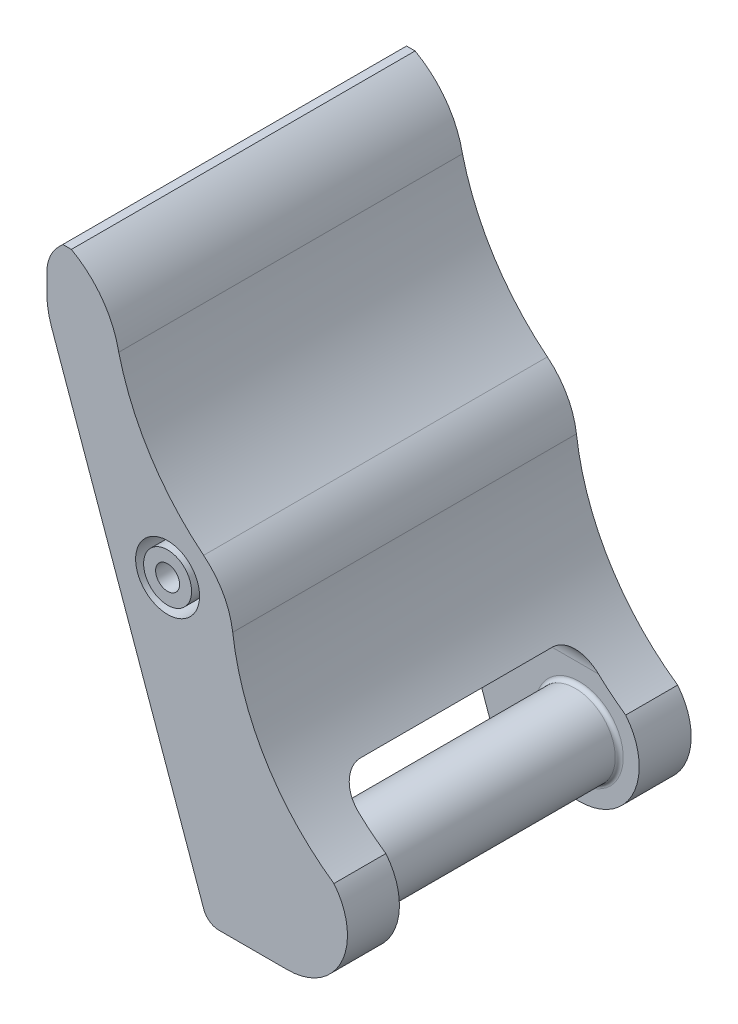
from build123d import *

# Parameters (mm, degrees)
EXTRUDE_1_DEPTH     = 21.5
FILLET_1_R          = 10
FILLET_2_R          = 2
CHAMFER_1_SIZE      = 2
FILLET_3_R          = 5
SKETCH_4_W          = 30
SKETCH_4_H          = 18
CUT_EXTRUDE_1_DEPTH = 41.107755842
FILLET_4_R          = 3
SKETCH_5_R          = 5
EXTRUDE_2_DEPTH     = 30
FILLET_5_R          = 0.5
CUT_EXTRUDE_2_DEPTH = 1
EXTRUDE_3_DEPTH     = 1
SKETCH_8_R          = 1.5
CUT_EXTRUDE_3_DEPTH = 44.0000001
SKETCH_9_R          = 4
SKETCH_9_R_2        = 3
CUT_EXTRUDE_4_DEPTH = 5


with BuildPart() as part:
    # 草图1 → 凸台-拉伸1 (new body, symmetric)
    with BuildSketch(Plane.XY):
        with BuildLine():
            Line((0, 0), (10, 0))
            ThreePointArc((10, 0), (16.777957438, 4.289191228), (15.803393387, 12.250855207))
            ThreePointArc((15.803393387, 12.250855207), (7.253184255, 21.345959317), (3.144852512, 33.133605616))
            ThreePointArc((3.144852512, 33.133605616), (1.958203293, 36.748513507), (-0.492803877, 39.658540875))
            ThreePointArc((-0.492803877, 39.658540875), (-7.169500574, 47.134089923), (-11.111969773, 56.349243149))
            ThreePointArc((-11.111969773, 56.349243149), (-13.171238931, 61.093425309), (-17.035891996, 64.530329514))
            Line((-17.035891996, 64.530329514), (-20.107755842, 64.530329514))
            Line((-20.107755842, 64.530329514), (-20.107755842, 56.530329514))
            Line((-20.107755842, 56.530329514), (0, 0))
        make_face()
    extrude(amount=EXTRUDE_1_DEPTH, both=True)

    # 圆角1
    fillet_1_edges = [part.edges().sort_by_distance(p)[0] for p in [
        (-20.107755842, 56.530329514, 0),
    ]]
    fillet(fillet_1_edges, radius=FILLET_1_R)

    # 圆角2
    fillet_2_edges = [part.edges().sort_by_distance(p)[0] for p in [
        (0, 0, 0),
    ]]
    fillet(fillet_2_edges, radius=FILLET_2_R)

    # 倒角1
    chamfer_1_edges = [part.edges().sort_by_distance(p)[0] for p in [
        (-20.107755842, 64.530329514, 0),
    ]]
    chamfer(chamfer_1_edges, length=CHAMFER_1_SIZE)

    # 圆角3
    fillet_3_edges = [part.edges().sort_by_distance(p)[0] for p in [
        (-20.107755842, 62.530329514, 0),
    ]]
    fillet(fillet_3_edges, radius=FILLET_3_R)

    # 草图4 → 切除-拉伸1 (cut, through all)
    with BuildSketch(Plane(origin=(20, 0, 0), x_dir=(0, 0, -1), z_dir=(1, 0, 0))):
        with Locations((0, 9)):
            Rectangle(SKETCH_4_W, SKETCH_4_H)
    extrude(amount=-CUT_EXTRUDE_1_DEPTH, mode=Mode.SUBTRACT)

    # 圆角4
    fillet_4_edges = [part.edges().sort_by_distance(p)[0] for p in [
        (1.602536732, 18, 15),
        (1.602536732, 18, -15),
    ]]
    fillet(fillet_4_edges, radius=FILLET_4_R)

    # 草图5 → 凸台-拉伸2 (add)
    with BuildSketch(Plane.XY.offset(-15)):
        with Locations((10, 7.5)):
            Circle(SKETCH_5_R)
    extrude(amount=EXTRUDE_2_DEPTH)

    # 圆角5
    fillet_5_edges = [part.edges().sort_by_distance(p)[0] for p in [
        (5, 7.5, -15),
        (5, 7.5, 15),
    ]]
    fillet(fillet_5_edges, radius=FILLET_5_R)

    # 草图6 → 切除-拉伸2 (cut)
    with BuildSketch(Plane(origin=(0, 0, 0), x_dir=(0, 0, 1), z_dir=(-0.942172159, -0.335129264, 0))):
        with BuildLine():
            Line((-9, 44.274461599), (9, 44.274461599))
            ThreePointArc((9, 44.274461599), (15, 38.274461599), (9, 32.274461599))
            Line((9, 32.274461599), (-9, 32.274461599))
            ThreePointArc((-9, 32.274461599), (-15, 38.274461599), (-9, 44.274461599))
        make_face()
    extrude(amount=-CUT_EXTRUDE_2_DEPTH, mode=Mode.SUBTRACT)

    # 草图7 → 凸台-拉伸3 (add)
    with BuildSketch(Plane(origin=(0.942172159, 0.335129264, 0), x_dir=(0, 0, 1), z_dir=(-0.942172159, -0.335129264, 0))):
        with BuildLine():
            Line((-8.417101523, 39.476144957), (-8.316419656, 39.783411099))
            Line((-8.316419656, 39.783411099), (-8.216483581, 39.778190557))
            Line((-8.216483581, 39.778190557), (-8.216483581, 38.52004012))
            Line((-8.216483581, 38.52004012), (-8.336556029, 38.514819579))
            Line((-8.336556029, 38.514819579), (-8.40666044, 39.048060576))
            add(Edge.make_bspline(
                [(-8.40666044, 39.048060576), (-8.416417829, 39.077797435), (-8.434613801, 39.133251923), (-8.466239834, 39.208160255), (-8.499805241, 39.268674041), (-8.535325718, 39.317468794), (-8.575497585, 39.357156801), (-8.61889069, 39.394825108), (-8.668408654, 39.430572463), (-8.723678879, 39.464577094), (-8.78387418, 39.49759227), (-8.84994874, 39.52743471), (-8.921737501, 39.554245618), (-9.025102803, 39.58563279), (-9.160690665, 39.617442753), (-9.272315315, 39.624161396), (-9.328458863, 39.627540653)],
                knots=[0, 0, 0, 0, 9.3869e-05, 0.000175051, 0.000243505, 0.000301081, 0.000355401, 0.000412512, 0.000473375, 0.000538357, 0.000607104, 0.000679195, 0.00075566, 0.000836811, 0.001003288, 0.001171752, 0.001171752, 0.001171752, 0.001171752], degree=3))
            add(Edge.make_bspline(
                [(-9.328458863, 39.627540653), (-9.362300887, 39.62684109), (-9.430936335, 39.625422298), (-9.517784573, 39.615080944), (-9.591370785, 39.601944581), (-9.652428291, 39.583983063), (-9.719570209, 39.56108533), (-9.789735842, 39.531815955), (-9.859228596, 39.499049515), (-9.922545225, 39.460709833), (-9.978028271, 39.418626329), (-10.024232996, 39.37191132), (-10.062713871, 39.324177375), (-10.095367962, 39.277048975), (-10.121009072, 39.229839439), (-10.140308971, 39.181511198), (-10.15356008, 39.129794032), (-10.164321251, 39.07278181), (-10.169903089, 39.008601557), (-10.175892929, 38.939526172), (-10.17188991, 38.867097017), (-10.15008854, 38.796402105), (-10.112857836, 38.729139204), (-10.077616557, 38.690654513), (-10.059334636, 38.670690025)],
                knots=[0, 0, 0, 0, 0.000101496, 0.000205846, 0.000262013, 0.000325528, 0.00039652, 0.000474771, 0.00055349, 0.000626779, 0.000696442, 0.000761834, 0.000823333, 0.000880219, 0.000933609, 0.000984159, 0.001035898, 0.001093532, 0.001158021, 0.001229012, 0.001301542, 0.001373976, 0.001449094, 0.00153007, 0.00153007, 0.00153007, 0.00153007], degree=3))
            add(Edge.make_bspline(
                [(-10.059334636, 38.670690025), (-10.037964617, 38.651404548), (-9.99424021, 38.611945247), (-9.917153461, 38.563598162), (-9.829578846, 38.524250813), (-9.73443606, 38.493312488), (-9.63793449, 38.470433962), (-9.547588409, 38.446890279), (-9.465036215, 38.42956343), (-9.412739362, 38.419074881), (-9.388122192, 38.414137713)],
                knots=[0, 0, 0, 0, 8.6232e-05, 0.000176435, 0.00027155, 0.000373669, 0.000476049, 0.000569022, 0.000653717, 0.000729042, 0.000729042, 0.000729042, 0.000729042], degree=3))
            Line((-9.388122192, 38.414137713), (-9.037600138, 38.34328751))
            add(Edge.make_bspline(
                [(-9.037600138, 38.34328751), (-8.994538912, 38.333313901), (-8.91217705, 38.31423769), (-8.794866713, 38.283424108), (-8.689121789, 38.253544448), (-8.594915095, 38.221858059), (-8.510381487, 38.18937593), (-8.433504413, 38.156479782), (-8.364702382, 38.12040836), (-8.302970028, 38.083072485), (-8.248093018, 38.043737621), (-8.200174477, 38.000806784), (-8.15989466, 37.95367438), (-8.115368259, 37.886601591), (-8.071087137, 37.796425177), (-8.033728905, 37.679682736), (-8.010045697, 37.552438984), (-8.000792419, 37.439858151), (-8.001524857, 37.345567425), (-8.011900649, 37.27516386), (-8.028151594, 37.205851396), (-8.046783262, 37.162228893), (-8.056138386, 37.140325652)],
                knots=[0, 0, 0, 0, 0.000132596, 0.000253612, 0.00036384, 0.000462186, 0.000551659, 0.000635487, 0.000712877, 0.000784504, 0.000851782, 0.000915144, 0.000977027, 0.001037219, 0.001156289, 0.001277043, 0.001403856, 0.001543767, 0.001615378, 0.00168615, 0.001756875, 0.001828198, 0.001828198, 0.001828198, 0.001828198], degree=3))
            add(Edge.make_bspline(
                [(-8.056138386, 37.140325652), (-8.066745046, 37.117139572), (-8.08806702, 37.070529892), (-8.130834842, 37.005993399), (-8.179255229, 36.943896095), (-8.23572964, 36.887944827), (-8.294552992, 36.836493267), (-8.353764045, 36.790542636), (-8.412665236, 36.751088358), (-8.472174209, 36.716368189), (-8.536279256, 36.686365858), (-8.608331828, 36.659999499), (-8.689330095, 36.634558415), (-8.779725752, 36.612367851), (-8.878262264, 36.593830975), (-8.984823535, 36.580292215), (-9.09890951, 36.573304873), (-9.177552046, 36.571973039), (-9.218081706, 36.571286658)],
                knots=[0, 0, 0, 0, 7.6381e-05, 0.000153544, 0.000231582, 0.000312269, 0.000391548, 0.000465985, 0.000536933, 0.000604092, 0.000672485, 0.00074895, 0.000834104, 0.000927077, 0.001028005, 0.001134754, 0.001249104, 0.001370705, 0.001370705, 0.001370705, 0.001370705], degree=3))
            add(Edge.make_bspline(
                [(-9.218081706, 36.571286658), (-9.263594024, 36.571429583), (-9.352266503, 36.571708045), (-9.481667202, 36.582158625), (-9.603694057, 36.601227793), (-9.718063093, 36.629761782), (-9.825180547, 36.665713541), (-9.925233362, 36.708041455), (-10.018239531, 36.757104924), (-10.105037475, 36.810620999), (-10.182512879, 36.87225439), (-10.252007262, 36.938537119), (-10.311036911, 37.011568658), (-10.360913192, 37.088541688), (-10.400087383, 37.168231572), (-10.429930578, 37.247165314), (-10.451236689, 37.324810954), (-10.456994338, 37.376626586), (-10.459824727, 37.402098505)],
                knots=[0, 0, 0, 0, 0.000136498, 0.000265942, 0.000389043, 0.000506616, 0.000619111, 0.000727713, 0.000832127, 0.000934344, 0.001033115, 0.00112858, 0.001221878, 0.001314142, 0.001403195, 0.00148769, 0.001567102, 0.001643886, 0.001643886, 0.001643886, 0.001643886], degree=3))
            Line((-10.459824727, 37.402098505), (-10.499351683, 37.6690919))
            Line((-10.499351683, 37.6690919), (-10.359888652, 37.6690919))
            add(Edge.make_bspline(
                [(-10.359888652, 37.6690919), (-10.351634666, 37.637465394), (-10.335713668, 37.576461474), (-10.30937037, 37.488730125), (-10.282628232, 37.407953955), (-10.255933255, 37.332877868), (-10.226231112, 37.263383267), (-10.190875955, 37.198792183), (-10.150295831, 37.138494248), (-10.105791864, 37.080817089), (-10.053349205, 37.028810295), (-9.995865664, 36.978883368), (-9.930608766, 36.933639234), (-9.859351816, 36.892405315), (-9.784631877, 36.855262315), (-9.70703555, 36.825578611), (-9.628670216, 36.80122106), (-9.523233162, 36.779364893), (-9.392882852, 36.762765421), (-9.288981089, 36.762892845), (-9.238218079, 36.7629551)],
                knots=[0, 0, 0, 0, 9.8051e-05, 0.000189129, 0.00027474, 0.000353303, 0.00042812, 0.000501212, 0.000573814, 0.000646029, 0.000719333, 0.000794968, 0.000874212, 0.000957098, 0.001041817, 0.001124223, 0.001206087, 0.001287709, 0.001447002, 0.001599173, 0.001599173, 0.001599173, 0.001599173], degree=3))
            add(Edge.make_bspline(
                [(-9.238218079, 36.7629551), (-9.193435432, 36.763782214), (-9.107654964, 36.765366537), (-8.984976686, 36.778150036), (-8.8738808, 36.798216311), (-8.774312928, 36.828448587), (-8.68493505, 36.866126789), (-8.603898157, 36.909378037), (-8.530711848, 36.958632007), (-8.467382357, 37.014285102), (-8.413416842, 37.07232671), (-8.36821035, 37.128856365), (-8.334816381, 37.185023823), (-8.310672362, 37.240102516), (-8.295532522, 37.297499603), (-8.287207994, 37.358325372), (-8.283036211, 37.424202142), (-8.285370312, 37.469469506), (-8.286587992, 37.493085081)],
                knots=[0, 0, 0, 0, 0.000134317, 0.000257282, 0.000369617, 0.000472483, 0.000568747, 0.000660173, 0.000747673, 0.000832775, 0.000912449, 0.00098525, 0.001049458, 0.00110792, 0.001165089, 0.001226895, 0.001291886, 0.001362772, 0.001362772, 0.001362772, 0.001362772], degree=3))
            add(Edge.make_bspline(
                [(-8.286587992, 37.493085081), (-8.292376734, 37.530066312), (-8.303288842, 37.599778028), (-8.332685966, 37.695662427), (-8.373084953, 37.775948345), (-8.424695222, 37.841255801), (-8.485607221, 37.894383317), (-8.552467892, 37.942280672), (-8.62632204, 37.985869063), (-8.709267653, 38.022995948), (-8.801728219, 38.057668631), (-8.905855484, 38.090040767), (-9.022548582, 38.120728902), (-9.104884242, 38.138068877), (-9.147977295, 38.147144318)],
                knots=[0, 0, 0, 0, 0.000112199, 0.000211501, 0.000299558, 0.000380276, 0.000459492, 0.000541247, 0.000626818, 0.000716254, 0.000813494, 0.00092294, 0.001043234, 0.001175332, 0.001175332, 0.001175332, 0.001175332], degree=3))
            Line((-9.147977295, 38.147144318), (-9.578299051, 38.227689812))
            add(Edge.make_bspline(
                [(-9.578299051, 38.227689812), (-9.612691087, 38.234526193), (-9.680091354, 38.247923885), (-9.777603188, 38.273904078), (-9.870689006, 38.301075664), (-9.958095621, 38.332188757), (-10.039384412, 38.366295408), (-10.113803017, 38.403290019), (-10.179953199, 38.444635499), (-10.240082976, 38.487603064), (-10.291673124, 38.536123496), (-10.337549418, 38.587683454), (-10.377353444, 38.643377729), (-10.411578473, 38.703109738), (-10.437440226, 38.769610542), (-10.454138786, 38.842666079), (-10.462573371, 38.923083409), (-10.460769014, 38.97868793), (-10.459824727, 39.00778783)],
                knots=[0, 0, 0, 0, 0.000105167, 0.000206103, 0.00030261, 0.000396022, 0.000484256, 0.000566971, 0.000644998, 0.00071809, 0.000788277, 0.000856963, 0.000924847, 0.000993301, 0.001062964, 0.001138037, 0.001217516, 0.001304777, 0.001304777, 0.001304777, 0.001304777], degree=3))
            add(Edge.make_bspline(
                [(-10.459824727, 39.00778783), (-10.459104336, 39.032935787), (-10.457706916, 39.081717993), (-10.447062749, 39.152226335), (-10.430253547, 39.217419045), (-10.405823569, 39.27768373), (-10.374199788, 39.333827086), (-10.338963199, 39.389323725), (-10.296308268, 39.442168911), (-10.249998546, 39.494210824), (-10.198882141, 39.542806885), (-10.145085726, 39.587663212), (-10.08913213, 39.628398127), (-10.008534459, 39.675915774), (-9.897118286, 39.725817082), (-9.776336741, 39.766645756), (-9.667702863, 39.791224331), (-9.57393313, 39.804284406), (-9.46952175, 39.811331907), (-9.396585047, 39.812584896), (-9.358290528, 39.813242763)],
                knots=[0, 0, 0, 0, 7.5417e-05, 0.000146295, 0.000213408, 0.000276975, 0.000340722, 0.000406504, 0.000473944, 0.000544179, 0.000615389, 0.000685287, 0.000754211, 0.000822767, 0.000965594, 0.001119597, 0.001204454, 0.001299378, 0.001403311, 0.001518201, 0.001518201, 0.001518201, 0.001518201], degree=3))
            add(Edge.make_bspline(
                [(-9.358290528, 39.813242763), (-9.315483408, 39.810820357), (-9.231348364, 39.806059251), (-9.10748452, 39.789371411), (-8.98802497, 39.765025563), (-8.874903885, 39.732388914), (-8.771060859, 39.69538259), (-8.679232297, 39.657673649), (-8.602138613, 39.616643073), (-8.557811632, 39.585913358), (-8.537173971, 39.571606283)],
                knots=[0, 0, 0, 0, 0.000128588, 0.000252733, 0.000374571, 0.000494019, 0.000605591, 0.000705184, 0.000791609, 0.000866901, 0.000866901, 0.000866901, 0.000866901], degree=3))
            Line((-8.537173971, 39.571606283), (-8.417101523, 39.476144957))
        make_face()
        with BuildLine():
            Line((-5.258674078, 38.247826185), (-3.466536852, 38.353728593))
            Line((-3.466536852, 38.353728593), (-3.466536852, 39.24494956))
            add(Edge.make_bspline(
                [(-3.466536852, 39.24494956), (-3.466919533, 39.27653867), (-3.467761296, 39.346023519), (-3.475586787, 39.434661249), (-3.481432416, 39.508598754), (-3.488095944, 39.558636239), (-3.495964223, 39.600836275), (-3.509167478, 39.646555544), (-3.528579924, 39.698636593), (-3.547283387, 39.738048114), (-3.556777636, 39.758054184)],
                knots=[0, 0, 0, 0, 9.4742e-05, 0.000208399, 0.000266804, 0.000317221, 0.000359784, 0.000395434, 0.000459853, 0.000526266, 0.000526266, 0.000526266, 0.000526266], degree=3))
            Line((-3.556777636, 39.758054184), (-3.597050383, 39.838599677))
            Line((-3.597050383, 39.838599677), (-3.506809599, 39.889313506))
            Line((-3.506809599, 39.889313506), (-3.075742051, 39.587267907))
            add(Edge.make_bspline(
                [(-3.075742051, 39.587267907), (-3.087223573, 39.57056542), (-3.107335712, 39.541307735), (-3.132520381, 39.496266803), (-3.149505088, 39.445737439), (-3.16442167, 39.396312141), (-3.176274188, 39.345530572), (-3.181439433, 39.297010356), (-3.185289837, 39.240786374), (-3.18583061, 39.200708525), (-3.186119209, 39.179319899)],
                knots=[0, 0, 0, 0, 6.0813e-05, 0.000106526, 0.000154186, 0.000220264, 0.000261519, 0.000310361, 0.00036642, 0.000430575, 0.000430575, 0.000430575, 0.000430575], degree=3))
            Line((-3.186119209, 39.179319899), (-3.186119209, 37.145546193))
            Line((-3.186119209, 37.145546193), (-3.226391955, 36.607084655))
            add(Edge.make_bspline(
                [(-3.226391955, 36.607084655), (-3.228163614, 36.594660305), (-3.231389325, 36.572038919), (-3.235370865, 36.541041065), (-3.240666568, 36.516432619), (-3.246869385, 36.493414657), (-3.255159004, 36.473021697), (-3.268516602, 36.457538541), (-3.284896616, 36.452898777), (-3.292669047, 36.458266375), (-3.296496366, 36.4609095)],
                knots=[0, 0, 0, 0, 3.7653e-05, 6.8556e-05, 9.3715e-05, 0.000113077, 0.000140111, 0.000159096, 0.000172848, 0.000186189, 0.000186189, 0.000186189, 0.000186189], degree=3))
            add(Edge.make_bspline(
                [(-3.296496366, 36.4609095), (-3.303726536, 36.464108), (-3.32344248, 36.472829987), (-3.331601894, 36.493385396), (-3.336769113, 36.506402788)],
                knots=[0, 0, 0, 0, 2.3035e-05, 6.2815e-05, 6.2815e-05, 6.2815e-05, 6.2815e-05], degree=3))
            Line((-3.336769113, 36.506402788), (-3.396432441, 36.566811908))
            Line((-3.396432441, 36.566811908), (-3.516504889, 36.742818727))
            add(Edge.make_bspline(
                [(-3.516504889, 36.742818727), (-3.529721133, 36.758564867), (-3.552364769, 36.785543023), (-3.577806782, 36.821525695), (-3.593627751, 36.846507644), (-3.592963541, 36.871412334), (-3.570818586, 36.889925251), (-3.550891359, 36.921032564), (-3.526071581, 36.959748784), (-3.506323782, 37.0069002), (-3.488857461, 37.05492869), (-3.477057383, 37.101002693), (-3.46771331, 37.142659821), (-3.466435504, 37.17486704), (-3.466566437, 37.201229669), (-3.466523298, 37.226341337), (-3.466542394, 37.261889253), (-3.466534793, 37.307880326), (-3.466537569, 37.364560272), (-3.466536612, 37.431681591), (-3.466536925, 37.509243893), (-3.466536877, 37.564432476), (-3.466536852, 37.593766948)],
                knots=[0, 0, 0, 0, 6.15e-05, 0.000105368, 0.000133393, 0.000147582, 0.000175775, 0.000213664, 0.000259837, 0.000312919, 0.000366699, 0.00041301, 0.000455572, 0.000494418, 0.000509334, 0.000534691, 0.000569743, 0.000615982, 0.000672662, 0.000739783, 0.000817346, 0.000905349, 0.000905349, 0.000905349, 0.000905349], degree=3))
            Line((-3.466536852, 37.593766948), (-3.466536852, 38.167280692))
            Line((-3.466536852, 38.167280692), (-5.26911516, 38.056903534))
            Line((-5.26911516, 38.056903534), (-5.258674078, 36.969539375))
            add(Edge.make_bspline(
                [(-5.258674078, 36.969539375), (-5.259474411, 36.940916951), (-5.261268297, 36.87676198), (-5.274393694, 36.778081225), (-5.286950553, 36.680091561), (-5.294003065, 36.595353202), (-5.299367458, 36.528633969), (-5.315691283, 36.479320789), (-5.334462898, 36.447863824), (-5.357698657, 36.428572447), (-5.38399707, 36.438366467), (-5.393388649, 36.452589032), (-5.398882899, 36.4609095)],
                knots=[0, 0, 0, 0, 8.5847e-05, 0.00019242, 0.000298338, 0.000382199, 0.000447599, 0.000498777, 0.000535389, 0.000559185, 0.000580186, 0.000609793, 0.000609793, 0.000609793, 0.000609793], degree=3))
            Line((-5.398882899, 36.4609095), (-5.46898731, 36.566811908))
            Line((-5.46898731, 36.566811908), (-5.58980555, 36.752514018))
            add(Edge.make_bspline(
                [(-5.58980555, 36.752514018), (-5.598802304, 36.764011847), (-5.614487637, 36.784057662), (-5.631568776, 36.812655414), (-5.643811529, 36.833175308), (-5.646577834, 36.856575847), (-5.631959844, 36.883626446), (-5.613340237, 36.923175887), (-5.586628622, 36.975458441), (-5.563911308, 37.039622417), (-5.543897596, 37.104861984), (-5.535923159, 37.153807904), (-5.532692084, 37.186772592), (-5.532414804, 37.210435425), (-5.531517607, 37.24100311), (-5.530834281, 37.278296919), (-5.530126375, 37.322297931), (-5.529160663, 37.373009226), (-5.529467811, 37.430687662), (-5.529421172, 37.47145729), (-5.52939643, 37.493085081)],
                knots=[0, 0, 0, 0, 4.3704e-05, 7.6195e-05, 0.000100211, 0.00011446, 0.000144662, 0.000188689, 0.000247398, 0.000319848, 0.000392787, 0.000451761, 0.000468236, 0.000492113, 0.000522699, 0.000559996, 0.000604004, 0.000654724, 0.00071215, 0.000777034, 0.000777034, 0.000777034, 0.000777034], degree=3))
            Line((-5.52939643, 37.493085081), (-5.52939643, 39.234508478))
            add(Edge.make_bspline(
                [(-5.52939643, 39.234508478), (-5.530233036, 39.266105294), (-5.532061919, 39.335178283), (-5.541856247, 39.423096259), (-5.551330651, 39.49608933), (-5.55850978, 39.546659478), (-5.566988167, 39.59029503), (-5.57645466, 39.638469036), (-5.588077002, 39.689532652), (-5.602586289, 39.726360898), (-5.609196132, 39.743138352)],
                knots=[0, 0, 0, 0, 9.4789e-05, 0.000207216, 0.000265124, 0.000315645, 0.000360405, 0.000398433, 0.000463008, 0.00051704, 0.00051704, 0.00051704, 0.00051704], degree=3))
            Line((-5.609196132, 39.743138352), (-5.659909961, 39.828904386))
            Line((-5.659909961, 39.828904386), (-5.569669177, 39.873651883))
            Line((-5.569669177, 39.873651883), (-5.128906338, 39.576826824))
            add(Edge.make_bspline(
                [(-5.128906338, 39.576826824), (-5.140736593, 39.560282023), (-5.161913618, 39.530665612), (-5.190743684, 39.485921681), (-5.213659514, 39.433824793), (-5.235834819, 39.370120369), (-5.255575457, 39.294714193), (-5.257643242, 39.241099949), (-5.258674078, 39.214372104)],
                knots=[0, 0, 0, 0, 6.1037e-05, 0.00010926, 0.000159317, 0.000231258, 0.000311755, 0.000391777, 0.000391777, 0.000391777, 0.000391777], degree=3))
            Line((-5.258674078, 39.214372104), (-5.258674078, 38.247826185))
        make_face()
        with BuildLine():
            Line((1.294596751, 37.900287297), (-0.067218719, 37.734721561))
            Line((-0.067218719, 37.734721561), (-0.387163317, 36.984455207))
            Line((-0.387163317, 36.984455207), (-0.537813221, 36.601864114))
            Line((-0.537813221, 36.601864114), (-0.597476549, 36.481045874))
            add(Edge.make_bspline(
                [(-0.597476549, 36.481045874), (-0.603783545, 36.472278646), (-0.615059436, 36.456604259), (-0.635778906, 36.439309826), (-0.657370673, 36.432634118), (-0.677923628, 36.430969162), (-0.697191474, 36.438756848), (-0.709240792, 36.454142291), (-0.714736702, 36.47474551), (-0.721541888, 36.500792229), (-0.729775744, 36.537573197), (-0.734831188, 36.565794605), (-0.737685371, 36.58172774)],
                knots=[0, 0, 0, 0, 3.238e-05, 5.789e-05, 7.9115e-05, 9.9266e-05, 0.000118656, 0.000138806, 0.000155315, 0.000182267, 0.00021972, 0.000268283, 0.000268283, 0.000268283, 0.000268283], degree=3))
            Line((-0.737685371, 36.58172774), (-0.787653409, 36.792786764))
            add(Edge.make_bspline(
                [(-0.787653409, 36.792786764), (-0.790564606, 36.810160416), (-0.795748848, 36.841099312), (-0.800363759, 36.882201489), (-0.801982887, 36.911878847), (-0.798709987, 36.938058941), (-0.781792201, 36.961307816), (-0.766251892, 36.976314523), (-0.757821744, 36.984455207)],
                knots=[0, 0, 0, 0, 5.2846e-05, 9.4108e-05, 0.000123949, 0.000142095, 0.000171899, 0.000207235, 0.000207235, 0.000207235, 0.000207235], degree=3))
            Line((-0.757821744, 36.984455207), (-0.707853707, 37.029948495))
            add(Edge.make_bspline(
                [(-0.707853707, 37.029948495), (-0.697057515, 37.041602592), (-0.672317333, 37.068308719), (-0.639694353, 37.121291482), (-0.604217751, 37.189312676), (-0.57454336, 37.255041286), (-0.549520884, 37.310263569), (-0.533005684, 37.348954133), (-0.516817604, 37.381909959), (-0.503580005, 37.410086006), (-0.492544602, 37.433415696), (-0.482927449, 37.451383086), (-0.474992899, 37.464166481), (-0.469742825, 37.470496352), (-0.46770881, 37.472948708)],
                knots=[0, 0, 0, 0, 4.7567e-05, 0.000109003, 0.000185733, 0.000277825, 0.000325229, 0.000367634, 0.000403995, 0.000435353, 0.000461037, 0.000481393, 0.000496495, 0.000506045, 0.000506045, 0.000506045, 0.000506045], degree=3))
            Line((-0.46770881, 37.472948708), (0.563720979, 39.873651883))
            Line((0.563720979, 39.873651883), (0.703929801, 39.873651883))
            Line((0.703929801, 39.873651883), (1.67495047, 37.714585188))
            Line((1.67495047, 37.714585188), (1.79576871, 37.462507625))
            add(Edge.make_bspline(
                [(1.79576871, 37.462507625), (1.807898178, 37.43402519), (1.82978905, 37.382621012), (1.863169839, 37.315374285), (1.889540334, 37.264044494), (1.908176394, 37.23715215), (1.915841158, 37.226091687)],
                knots=[0, 0, 0, 0, 9.2838e-05, 0.000167552, 0.000225287, 0.000265622, 0.000265622, 0.000265622, 0.000265622], degree=3))
            Line((1.915841158, 37.226091687), (1.985945569, 37.130630361))
            add(Edge.make_bspline(
                [(1.985945569, 37.130630361), (1.99418142, 37.116580733), (2.009432436, 37.090563857), (2.033837404, 37.056076646), (2.059335938, 37.030483511), (2.084168839, 37.012230797), (2.106589444, 37.00069039), (2.123448581, 36.990136208), (2.134383228, 36.981629588), (2.142652139, 36.973292338), (2.145219576, 36.959919577), (2.141218015, 36.945390035), (2.137173182, 36.926935357), (2.135120959, 36.903336062), (2.129833821, 36.871198035), (2.127475675, 36.846755069), (2.12615439, 36.833059511)],
                knots=[0, 0, 0, 0, 4.8859e-05, 9.0477e-05, 0.000126337, 0.000156769, 0.000182485, 0.000201933, 0.000216259, 0.000224187, 0.000236487, 0.000254633, 0.000269113, 0.000293164, 0.000325544, 0.000366806, 0.000366806, 0.000366806, 0.000366806], degree=3))
            Line((2.12615439, 36.833059511), (2.085881644, 36.607084655))
            Line((2.085881644, 36.607084655), (2.06574527, 36.52131862))
            add(Edge.make_bspline(
                [(2.06574527, 36.52131862), (2.064233264, 36.511574389), (2.061526065, 36.494127648), (2.054986519, 36.471478898), (2.047319723, 36.454902566), (2.034160331, 36.442159284), (2.013491428, 36.438989528), (1.99015765, 36.441438458), (1.967435088, 36.453578524), (1.959454393, 36.46829182), (1.955368113, 36.475825333)],
                knots=[0, 0, 0, 0, 2.9551e-05, 5.291e-05, 7.059e-05, 8.3784e-05, 0.000106033, 0.000130084, 0.000154135, 0.000179371, 0.000179371, 0.000179371, 0.000179371], degree=3))
            Line((1.955368113, 36.475825333), (1.885263702, 36.677189066))
            Line((1.885263702, 36.677189066), (1.294596751, 37.900287297))
        make_face()
        with BuildLine():
            Line((1.274460378, 37.976358041), (0.63382539, 39.390378923))
            Line((0.63382539, 39.390378923), (-0.017250681, 37.91072838))
            add(Edge.make_bspline(
                [(-0.017250681, 37.91072838), (0.012580148, 37.913222356), (0.068518168, 37.917898999), (0.146629043, 37.924310458), (0.213507261, 37.931061303), (0.272437903, 37.938013603), (0.329991053, 37.946387919), (0.392555148, 37.953890452), (0.462712405, 37.96521036), (0.537558197, 37.974878412), (0.609021606, 37.987515543), (0.670372016, 37.998141647), (0.717375799, 38.008596448), (0.743256469, 38.017460784), (0.753897838, 38.021105537)],
                knots=[0, 0, 0, 0, 8.9805e-05, 0.0001684, 0.000235114, 0.00029145, 0.000346401, 0.000409583, 0.00048046, 0.000559563, 0.000635948, 0.000698118, 0.000746416, 0.000780142, 0.000780142, 0.000780142, 0.000780142], degree=3))
            Line((0.753897838, 38.021105537), (1.004483817, 38.106871572))
            Line((1.004483817, 38.106871572), (1.274460378, 37.976358041))
        make_face(mode=Mode.SUBTRACT)
        with BuildLine():
            add(Edge.make_bspline(
                [(6.0162034, 38.212773979), (6.032091868, 38.201308581), (6.062134681, 38.179629158), (6.105169163, 38.149270303), (6.142158106, 38.120740042), (6.185953998, 38.087127304), (6.234592792, 38.039369714), (6.274974319, 37.963374901), (6.305609664, 37.873271402), (6.328642376, 37.769189523), (6.343578077, 37.654100752), (6.345571207, 37.574175106), (6.34658908, 37.533357828)],
                knots=[0, 0, 0, 0, 5.878e-05, 0.000111145, 0.000157982, 0.000198865, 0.00027692, 0.000360082, 0.000454197, 0.000562027, 0.000679323, 0.000801744, 0.000801744, 0.000801744, 0.000801744], degree=3))
            Line((6.34658908, 37.533357828), (6.376420744, 37.0650007))
            add(Edge.make_bspline(
                [(6.376420744, 37.0650007), (6.376818701, 37.03888803), (6.377589861, 36.988286974), (6.383314133, 36.926658462), (6.391751841, 36.882007554), (6.401433903, 36.853343961), (6.414899689, 36.829976636), (6.43176521, 36.807404492), (6.464262235, 36.793401503), (6.511572783, 36.784063481), (6.577965254, 36.779055277), (6.628503227, 36.778296408), (6.656838388, 36.777870932)],
                knots=[0, 0, 0, 0, 7.834e-05, 0.000151807, 0.000185301, 0.000214549, 0.000241931, 0.000266281, 0.000297301, 0.000344704, 0.000411347, 0.000496397, 0.000496397, 0.000496397, 0.000496397], degree=3))
            add(Edge.make_bspline(
                [(6.656838388, 36.777870932), (6.684958275, 36.777251046), (6.737050784, 36.776102698), (6.810231335, 36.787112347), (6.872316794, 36.813108184), (6.919949222, 36.857311116), (6.954378875, 36.912998844), (6.97430172, 36.980404002), (6.989725394, 37.058465198), (7.001117723, 37.114719954), (7.007360442, 37.145546193)],
                knots=[0, 0, 0, 0, 8.4278e-05, 0.000156126, 0.000220567, 0.000282875, 0.000347857, 0.0004146, 0.00049242, 0.000586759, 0.000586759, 0.000586759, 0.000586759], degree=3))
            Line((7.007360442, 37.145546193), (7.057328479, 37.432675961))
            Line((7.057328479, 37.432675961), (7.18784201, 37.432675961))
            Line((7.18784201, 37.432675961), (7.18784201, 37.079916532))
            add(Edge.make_bspline(
                [(7.18784201, 37.079916532), (7.187541041, 37.046591619), (7.186985343, 36.985061594), (7.179970692, 36.900695842), (7.167947738, 36.832063998), (7.150499074, 36.776984615), (7.123831207, 36.733444055), (7.090716247, 36.695803195), (7.047026214, 36.66556782), (6.996314868, 36.640608767), (6.939852197, 36.620828588), (6.87885051, 36.606051156), (6.814283787, 36.595567222), (6.747405258, 36.59073762), (6.682197568, 36.590075801), (6.621538962, 36.58883378), (6.567083086, 36.589737276), (6.532786838, 36.590883184), (6.516629566, 36.591423031)],
                knots=[0, 0, 0, 0, 9.9961e-05, 0.000184565, 0.000253606, 0.000308795, 0.00035663, 0.000405745, 0.00045811, 0.00051481, 0.00057496, 0.000637184, 0.000702902, 0.00077097, 0.000838108, 0.000898521, 0.000952969, 0.001001469, 0.001001469, 0.001001469, 0.001001469], degree=3))
            add(Edge.make_bspline(
                [(6.516629566, 36.591423031), (6.492964466, 36.592418967), (6.448167433, 36.594304232), (6.385176434, 36.604566411), (6.329895344, 36.617095069), (6.282142686, 36.635376069), (6.240920973, 36.658747279), (6.205269212, 36.688253944), (6.175247283, 36.724130526), (6.148906337, 36.766141953), (6.12863864, 36.818190545), (6.113879906, 36.881235378), (6.101761659, 36.956240798), (6.098014875, 37.010506633), (6.096003101, 37.039643786)],
                knots=[0, 0, 0, 0, 7.0991e-05, 0.000134384, 0.000191181, 0.000240764, 0.000287201, 0.000332749, 0.000378777, 0.000427001, 0.000480874, 0.000545448, 0.000620976, 0.000708552, 0.000708552, 0.000708552, 0.000708552], degree=3))
            Line((6.096003101, 37.039643786), (6.08630781, 37.281280265))
            Line((6.08630781, 37.281280265), (6.075866728, 37.528137286))
            add(Edge.make_bspline(
                [(6.075866728, 37.528137286), (6.072178801, 37.560497039), (6.064324895, 37.629411212), (6.049296269, 37.71649145), (6.036140569, 37.788461943), (6.021505441, 37.83889858), (6.005387523, 37.884377979), (5.98666306, 37.925611254), (5.96363485, 37.963178901), (5.935959058, 37.998069418), (5.903357684, 38.031486666), (5.85289508, 38.072673001), (5.779935024, 38.117161832), (5.696533563, 38.144373323), (5.62379452, 38.160161899), (5.562375505, 38.168430217), (5.495557972, 38.176394201), (5.395763931, 38.181645136), (5.258254312, 38.185987413), (5.144872622, 38.183510716), (5.084709685, 38.182196524)],
                knots=[0, 0, 0, 0, 9.7684e-05, 0.000208031, 0.000265073, 0.000317012, 0.000365373, 0.000409753, 0.000452602, 0.000497212, 0.000543095, 0.000592368, 0.000692388, 0.000797343, 0.000853807, 0.000915613, 0.000983148, 0.001055628, 0.00121529, 0.001395785, 0.001395785, 0.001395785, 0.001395785], degree=3))
            Line((5.084709685, 38.182196524), (4.59397881, 38.16206015))
            Line((4.59397881, 38.16206015), (4.59397881, 36.974014124))
            add(Edge.make_bspline(
                [(4.59397881, 36.974014124), (4.589511405, 36.934982834), (4.581372648, 36.863875292), (4.570316251, 36.768157381), (4.561362246, 36.693806529), (4.552662949, 36.625922245), (4.544399761, 36.560267787), (4.528450464, 36.505802686), (4.516060696, 36.470071433), (4.505834125, 36.454429614), (4.495279708, 36.443584216), (4.487703044, 36.4452541), (4.484347444, 36.445993668)],
                knots=[0, 0, 0, 0, 0.000117856, 0.000214712, 0.000289085, 0.00034246, 0.000420198, 0.000486787, 0.000513239, 0.000532062, 0.000544294, 0.000554018, 0.000554018, 0.000554018, 0.000554018], degree=3))
            add(Edge.make_bspline(
                [(4.484347444, 36.445993668), (4.480117199, 36.44668684), (4.469760665, 36.44838387), (4.450164952, 36.453420897), (4.424828964, 36.471892134), (4.398571687, 36.500850035), (4.37185189, 36.532158254), (4.365923719, 36.556841727), (4.363529204, 36.566811908)],
                knots=[0, 0, 0, 0, 1.2874e-05, 3.1519e-05, 6.0065e-05, 0.000104893, 0.000149802, 0.000180233, 0.000180233, 0.000180233, 0.000180233], degree=3))
            Line((4.363529204, 36.566811908), (4.243456756, 36.748039268))
            add(Edge.make_bspline(
                [(4.243456756, 36.748039268), (4.231976465, 36.764382391), (4.211947076, 36.792895848), (4.186949238, 36.829972643), (4.172498149, 36.854621155), (4.16533343, 36.876725397), (4.182722853, 36.897765542), (4.20565162, 36.92336285), (4.234977519, 36.960102717), (4.258698062, 37.006443117), (4.279364608, 37.052467802), (4.292871661, 37.09152563), (4.299796218, 37.127970389), (4.304724476, 37.168806549), (4.308561681, 37.224106386), (4.313849986, 37.288203019), (4.317227362, 37.350676286), (4.321796171, 37.400559961), (4.322900901, 37.432681518), (4.323743866, 37.448089532), (4.324002249, 37.452812334)],
                knots=[0, 0, 0, 0, 5.9998e-05, 0.000104677, 0.000133368, 0.00014712, 0.000170155, 0.000206638, 0.00025452, 0.000308922, 0.000362686, 0.000405845, 0.000432465, 0.000473815, 0.000529184, 0.000598739, 0.000666753, 0.00071686, 0.000748964, 0.000763154, 0.000763154, 0.000763154, 0.000763154], degree=3))
            Line((4.324002249, 37.452812334), (4.324002249, 39.420956379))
            add(Edge.make_bspline(
                [(4.324002249, 39.420956379), (4.323144053, 39.436215825), (4.321479843, 39.465806863), (4.308348375, 39.508316479), (4.285829442, 39.546267084), (4.264608061, 39.56657674), (4.253897838, 39.576826824)],
                knots=[0, 0, 0, 0, 4.5713e-05, 8.8646e-05, 0.000132133, 0.000176443, 0.000176443, 0.000176443, 0.000176443], degree=3))
            Line((4.253897838, 39.576826824), (4.153961763, 39.652151776))
            add(Edge.make_bspline(
                [(4.153961763, 39.652151776), (4.143645118, 39.661019156), (4.125788236, 39.676367532), (4.107016267, 39.700075199), (4.095021764, 39.71835526), (4.097152425, 39.738310346), (4.121398341, 39.746538176), (4.155609582, 39.749145748), (4.209450861, 39.749002015), (4.25050956, 39.745274206), (4.274034211, 39.743138352)],
                knots=[0, 0, 0, 0, 4.0637e-05, 7.0338e-05, 9.1019e-05, 0.000104629, 0.000123318, 0.000158655, 0.000211606, 0.000282648, 0.000282648, 0.000282648, 0.000282648], degree=3))
            Line((4.274034211, 39.743138352), (4.484347444, 39.732697269))
            Line((4.484347444, 39.732697269), (4.694660676, 39.717781437))
            Line((4.694660676, 39.717781437), (5.084709685, 39.732697269))
            add(Edge.make_bspline(
                [(5.084709685, 39.732697269), (5.124983804, 39.733898368), (5.202055029, 39.736196871), (5.31291347, 39.740165717), (5.414093729, 39.743167434), (5.505836621, 39.745242464), (5.588124983, 39.747410776), (5.660699571, 39.749944956), (5.723860705, 39.751109224), (5.794925754, 39.75354457), (5.876920991, 39.753560936), (5.972119156, 39.744960071), (6.065363384, 39.730196659), (6.155618719, 39.708763558), (6.240463407, 39.681697708), (6.31780046, 39.649496048), (6.386916495, 39.61355678), (6.447142099, 39.570938369), (6.499806959, 39.521837531), (6.544516882, 39.463573255), (6.57988041, 39.395299632), (6.60896307, 39.319238523), (6.629961515, 39.235223983), (6.645415236, 39.144973067), (6.655479897, 39.048285888), (6.656376178, 38.981711122), (6.656838388, 38.94737871)],
                knots=[0, 0, 0, 0, 0.000120876, 0.000231316, 0.000332787, 0.000424547, 0.000506615, 0.000579736, 0.000642401, 0.000696118, 0.000793074, 0.000888144, 0.000982554, 0.001076076, 0.001166172, 0.001249413, 0.001327151, 0.00139937, 0.001470067, 0.001542413, 0.001618483, 0.001699925, 0.001786208, 0.001877798, 0.001974492, 0.002077455, 0.002077455, 0.002077455, 0.002077455], degree=3))
            add(Edge.make_bspline(
                [(6.656838388, 38.94737871), (6.656419966, 38.914533259), (6.655634855, 38.852903412), (6.646042348, 38.767284006), (6.631116151, 38.694491447), (6.602390909, 38.616418959), (6.552762832, 38.533591337), (6.48432966, 38.445562874), (6.406839117, 38.369575604), (6.337338897, 38.317003203), (6.281010654, 38.283902648), (6.241432619, 38.263929738), (6.203291292, 38.250250442), (6.178108997, 38.245073089), (6.166107512, 38.242605644)],
                knots=[0, 0, 0, 0, 9.849e-05, 0.000184802, 0.000258091, 0.000320853, 0.00043343, 0.000546067, 0.000654707, 0.000758074, 0.00080655, 0.000850577, 0.000890912, 0.000927638, 0.000927638, 0.000927638, 0.000927638], degree=3))
            Line((6.166107512, 38.242605644), (6.0162034, 38.212773979))
        make_face()
        with BuildLine():
            Line((4.584283519, 38.348508051), (5.575440561, 38.368644425))
            add(Edge.make_bspline(
                [(5.575440561, 38.368644425), (5.614982712, 38.369813014), (5.689919843, 38.37202763), (5.795450889, 38.380064815), (5.887893855, 38.391618585), (5.967819632, 38.407371143), (6.037383353, 38.426003659), (6.09794834, 38.447580989), (6.150500898, 38.471268548), (6.195984083, 38.497676219), (6.235065294, 38.528980319), (6.268658632, 38.565938382), (6.298091522, 38.608247345), (6.323425116, 38.657424222), (6.343898835, 38.716527051), (6.357902669, 38.788285471), (6.368357325, 38.873249687), (6.372048378, 38.96821408), (6.370927332, 39.064814817), (6.359997878, 39.155161787), (6.340253147, 39.235662509), (6.317304475, 39.28279229), (6.306316334, 39.30535868)],
                knots=[0, 0, 0, 0, 0.000118665, 0.000224885, 0.00031739, 0.000397981, 0.000469082, 0.000533246, 0.000590647, 0.000641809, 0.000690611, 0.000740227, 0.000791122, 0.000844824, 0.000905678, 0.000978081, 0.00106374, 0.001162286, 0.001262993, 0.001353185, 0.00143495, 0.001510068, 0.001510068, 0.001510068, 0.001510068], degree=3))
            add(Edge.make_bspline(
                [(6.306316334, 39.30535868), (6.294127699, 39.326748536), (6.270402268, 39.368384335), (6.222814065, 39.421522763), (6.168229907, 39.46466134), (6.10446148, 39.49646895), (6.031479779, 39.520246594), (5.947267642, 39.538460554), (5.850445419, 39.550825323), (5.781811989, 39.554660375), (5.745481047, 39.556690451)],
                knots=[0, 0, 0, 0, 7.3679e-05, 0.000143417, 0.000212491, 0.000281201, 0.000355962, 0.000442275, 0.000539314, 0.000648454, 0.000648454, 0.000648454, 0.000648454], degree=3))
            add(Edge.make_bspline(
                [(5.745481047, 39.556690451), (5.733796691, 39.556728836), (5.704956905, 39.55682358), (5.653502228, 39.555740741), (5.586130994, 39.55513224), (5.50259732, 39.554555842), (5.403414279, 39.552742767), (5.288056785, 39.551585815), (5.156806298, 39.549014447), (5.063828244, 39.547694137), (5.014605275, 39.54699516)],
                knots=[0, 0, 0, 0, 3.5052e-05, 8.6517e-05, 0.000154388, 0.000237175, 0.000337122, 0.000451983, 0.000583262, 0.000730945, 0.000730945, 0.000730945, 0.000730945], degree=3))
            Line((5.014605275, 39.54699516), (4.59397881, 39.536554077))
            Line((4.59397881, 39.536554077), (4.584283519, 38.348508051))
        make_face(mode=Mode.SUBTRACT)
        with BuildLine():
            Line((9.496067026, 38.112092113), (10.967513862, 39.219592646))
            add(Edge.make_bspline(
                [(10.967513862, 39.219592646), (10.976487455, 39.226772499), (10.999379405, 39.245088554), (11.040134298, 39.279426676), (11.094765974, 39.326455469), (11.158240048, 39.383603494), (11.224323663, 39.441991318), (11.281339019, 39.49792833), (11.327460906, 39.54541922), (11.373618036, 39.600138217), (11.419320715, 39.672658333), (11.444824758, 39.735453213), (11.458244738, 39.768495266)],
                knots=[0, 0, 0, 0, 3.4476e-05, 8.795e-05, 0.000159864, 0.000250722, 0.000344184, 0.000424349, 0.000490287, 0.000542711, 0.000638921, 0.000745767, 0.000745767, 0.000745767, 0.000745767], degree=3))
            Line((11.458244738, 39.768495266), (11.508212775, 39.889313506))
            Line((11.508212775, 39.889313506), (11.638726306, 39.889313506))
            Line((11.638726306, 39.889313506), (11.718526008, 39.441092752))
            add(Edge.make_bspline(
                [(11.718526008, 39.441092752), (11.693596761, 39.432840401), (11.646401119, 39.417217186), (11.588514364, 39.395066996), (11.54174622, 39.374567461), (11.500886503, 39.353056658), (11.451891531, 39.327446754), (11.379947253, 39.28658091), (11.292265085, 39.236626525), (11.22772142, 39.19025738), (11.197963468, 39.168878816)],
                knots=[0, 0, 0, 0, 7.8772e-05, 0.00014913, 0.000185856, 0.000231884, 0.000287599, 0.000351707, 0.000480122, 0.000589976, 0.000589976, 0.000589976, 0.000589976], degree=3))
            Line((11.197963468, 39.168878816), (10.487224069, 38.600585614))
            Line((10.487224069, 38.600585614), (11.46868582, 37.140325652))
            add(Edge.make_bspline(
                [(11.46868582, 37.140325652), (11.475030909, 37.130547486), (11.490067138, 37.107375751), (11.519506431, 37.069736416), (11.558634547, 37.023737455), (11.603524201, 36.971451077), (11.650338634, 36.919798984), (11.693366421, 36.874024837), (11.730736826, 36.837821283), (11.762497598, 36.807485314), (11.79716731, 36.784124578), (11.837111696, 36.762858197), (11.885464083, 36.742906183), (11.9588485, 36.717728258), (12.054102193, 36.692318889), (12.132050055, 36.682119456), (12.169729928, 36.677189066)],
                knots=[0, 0, 0, 0, 3.4957e-05, 8.2839e-05, 0.000143188, 0.000216154, 0.000289549, 0.000352324, 0.000404535, 0.000445722, 0.000483787, 0.0005295, 0.000581304, 0.000640504, 0.000762242, 0.000876155, 0.000876155, 0.000876155, 0.000876155], degree=3))
            Line((12.169729928, 36.677189066), (12.319634041, 36.657052692))
            Line((12.319634041, 36.657052692), (12.319634041, 36.571286658))
            Line((12.319634041, 36.571286658), (11.46868582, 36.571286658))
            add(Edge.make_bspline(
                [(11.46868582, 36.571286658), (11.461850809, 36.590637567), (11.447709466, 36.63067376), (11.428514986, 36.692620488), (11.407429846, 36.755512152), (11.382327225, 36.808789627), (11.354459232, 36.859720099), (11.319431396, 36.914208845), (11.273463269, 36.986875659), (11.237863362, 37.040468709), (11.218099841, 37.070221241)],
                knots=[0, 0, 0, 0, 6.1558e-05, 0.000127361, 0.000194586, 0.000260322, 0.000303712, 0.000368695, 0.000454552, 0.000561699, 0.000561699, 0.000561699, 0.000561699], degree=3))
            Line((11.218099841, 37.070221241), (10.286606127, 38.459631001))
            Line((10.286606127, 38.459631001), (9.496067026, 37.86001455))
            Line((9.496067026, 37.86001455), (9.496067026, 36.989675748))
            Line((9.496067026, 36.989675748), (9.46548957, 36.627221028))
            add(Edge.make_bspline(
                [(9.46548957, 36.627221028), (9.463853911, 36.606042965), (9.46081982, 36.566758408), (9.45153222, 36.5128113), (9.441414121, 36.467599809), (9.426742919, 36.432720647), (9.413281473, 36.405910453), (9.399796444, 36.389501521), (9.387390718, 36.377943919), (9.378837498, 36.379648717), (9.375248786, 36.380364007)],
                knots=[0, 0, 0, 0, 6.3672e-05, 0.00011811, 0.000164235, 0.000202043, 0.000231744, 0.000252943, 0.000267424, 0.000277891, 0.000277891, 0.000277891, 0.000277891], degree=3))
            add(Edge.make_bspline(
                [(9.375248786, 36.380364007), (9.371270972, 36.381073648), (9.361184278, 36.38287311), (9.341618247, 36.387718795), (9.316377881, 36.407338813), (9.290332008, 36.43738885), (9.264482626, 36.468666874), (9.257726331, 36.49227279), (9.255176338, 36.501182247)],
                knots=[0, 0, 0, 0, 1.2141e-05, 3.0785e-05, 5.9747e-05, 0.000105654, 0.000151172, 0.000178766, 0.000178766, 0.000178766, 0.000178766], degree=3))
            Line((9.255176338, 36.501182247), (9.165681345, 36.682409607))
            add(Edge.make_bspline(
                [(9.165681345, 36.682409607), (9.15541742, 36.700966467), (9.137580783, 36.733214557), (9.1157336, 36.775213344), (9.102797208, 36.801844709), (9.094048408, 36.818461268), (9.09808072, 36.830282164), (9.10549414, 36.841156853), (9.115808184, 36.856636682), (9.136155223, 36.879152151), (9.158786271, 36.908194917), (9.182858115, 36.943938323), (9.197693779, 36.988099862), (9.211363328, 37.041465198), (9.223641949, 37.101420915), (9.230382159, 37.15460023), (9.23324186, 37.202695507), (9.234315705, 37.251199041), (9.236285527, 37.312342459), (9.235962446, 37.357348748), (9.235785756, 37.381962132)],
                knots=[0, 0, 0, 0, 6.3747e-05, 0.000110779, 0.000140796, 0.000154947, 0.00016345, 0.000176496, 0.000194703, 0.000219053, 0.000267392, 0.000305258, 0.000347506, 0.000406116, 0.000470764, 0.000530891, 0.000566759, 0.000615259, 0.000676432, 0.000750265, 0.000750265, 0.000750265, 0.000750265], degree=3))
            Line((9.235785756, 37.381962132), (9.235785756, 39.345631427))
            add(Edge.make_bspline(
                [(9.235785756, 39.345631427), (9.235551095, 39.359303804), (9.23504755, 39.388642569), (9.23393178, 39.435682293), (9.229542308, 39.488825422), (9.225453155, 39.546024833), (9.220907902, 39.602324852), (9.214208115, 39.652600015), (9.206468356, 39.694587998), (9.193166488, 39.739552983), (9.173564392, 39.790559541), (9.155015051, 39.82927512), (9.145544972, 39.84904076)],
                knots=[0, 0, 0, 0, 4.1025e-05, 8.8034e-05, 0.000141116, 0.000200947, 0.000260095, 0.000310512, 0.000353075, 0.000388008, 0.00045103, 0.000516766, 0.000516766, 0.000516766, 0.000516766], degree=3))
            Line((9.145544972, 39.84904076), (9.105272225, 39.929586253))
            Line((9.105272225, 39.929586253), (9.19551301, 39.979554291))
            Line((9.19551301, 39.979554291), (9.605698392, 39.682729232))
            add(Edge.make_bspline(
                [(9.605698392, 39.682729232), (9.594305607, 39.66648718), (9.574421142, 39.638139018), (9.552821459, 39.602313628), (9.54213519, 39.572989756), (9.533169921, 39.546782109), (9.524588364, 39.513511496), (9.510592194, 39.458939835), (9.498910154, 39.378392647), (9.497057333, 39.310870739), (9.496067026, 39.274781224)],
                knots=[0, 0, 0, 0, 5.9575e-05, 0.000103979, 0.000124754, 0.000153055, 0.000187069, 0.000227767, 0.000322062, 0.000430328, 0.000430328, 0.000430328, 0.000430328], degree=3))
            Line((9.496067026, 39.274781224), (9.496067026, 38.112092113))
        make_face()
    extrude(amount=EXTRUDE_3_DEPTH)

    # 草图8 → 切除-拉伸3 (cut, through all)
    with BuildSketch(Plane.XY.offset(21.5)):
        with Locations((-5, 35)):
            Circle(SKETCH_8_R)
    extrude(amount=-CUT_EXTRUDE_3_DEPTH, mode=Mode.SUBTRACT)

    # 草图9 → 切除-拉伸4 (cut)
    with BuildSketch(Plane.XY.offset(21.5)):
        with Locations((-5, 35)):
            Circle(SKETCH_9_R)
        with Locations((-5, 35)):
            Circle(SKETCH_9_R_2, mode=Mode.SUBTRACT)
    cut_extrude_4 = extrude(amount=-CUT_EXTRUDE_4_DEPTH, mode=Mode.SUBTRACT)

    # 镜向1: 切除-拉伸4 across plane
    add(cut_extrude_4.mirror(Plane.XY), mode=Mode.SUBTRACT)


solid = part.part
